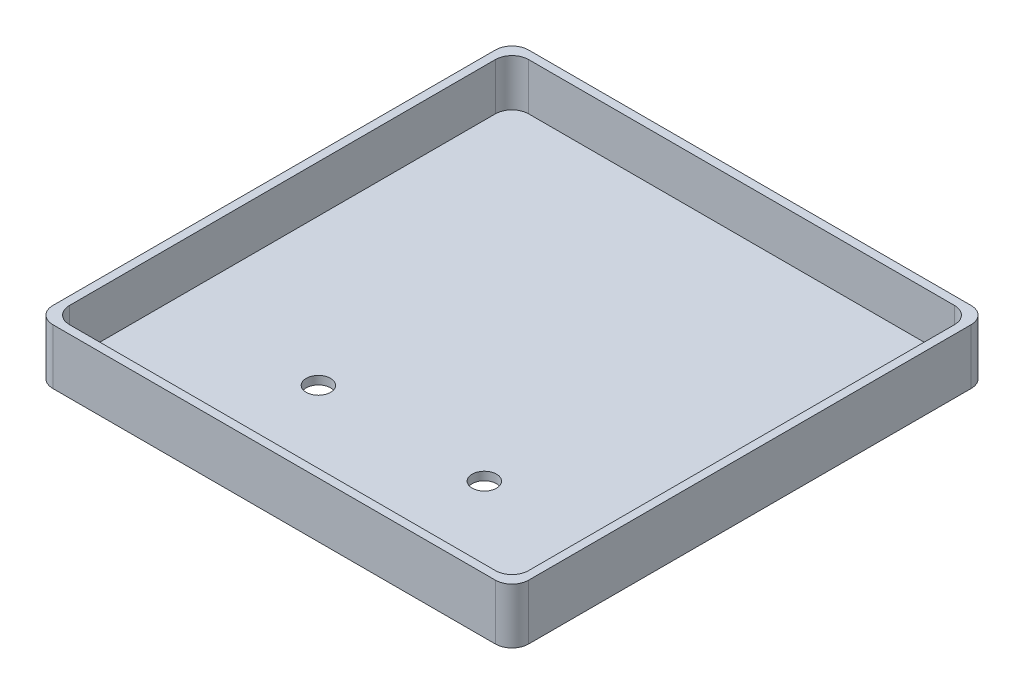
from build123d import *

# Parameters (mm, degrees)
EXTRUDE_1_DEPTH     = 10
CUT_EXTRUDE_1_DEPTH = 8.5
SKETCH_3_R          = 2.2
CUT_EXTRUDE_2_DEPTH = 11


with BuildPart() as part:
    # Эскиз1 → Бобышка-Вытянуть1 (new body)
    with BuildSketch(Plane(origin=(0, 0, 0), x_dir=(1, 0, 0), z_dir=(0, 1, 0))):
        with BuildLine():
            Line((-40, 43), (40, 43))
            ThreePointArc((40, 43), (42.121320344, 42.121320344), (43, 40))
            Line((43, 40), (43, -40))
            ThreePointArc((43, -40), (42.121320344, -42.121320344), (40, -43))
            Line((40, -43), (-40, -43))
            ThreePointArc((-40, -43), (-42.121320344, -42.121320344), (-43, -40))
            Line((-43, -40), (-43, 40))
            ThreePointArc((-43, 40), (-42.121320344, 42.121320344), (-40, 43))
        make_face()
    extrude(amount=EXTRUDE_1_DEPTH)

    # Эскиз2 → Вырез-Вытянуть1 (cut)
    with BuildSketch(Plane(origin=(0, 10, 0), x_dir=(1, 0, 0), z_dir=(0, 1, 0))):
        with BuildLine():
            Line((-38.5, -41.5), (38.5, -41.5))
            ThreePointArc((38.5, -41.5), (40.621320344, -40.621320344), (41.5, -38.5))
            Line((41.5, -38.5), (41.5, 38.5))
            ThreePointArc((41.5, 38.5), (40.621320344, 40.621320344), (38.5, 41.5))
            Line((38.5, 41.5), (-38.5, 41.5))
            ThreePointArc((-38.5, 41.5), (-40.621320344, 40.621320344), (-41.5, 38.5))
            Line((-41.5, 38.5), (-41.5, -38.5))
            ThreePointArc((-41.5, -38.5), (-40.621320344, -40.621320344), (-38.5, -41.5))
        make_face()
    extrude(amount=-CUT_EXTRUDE_1_DEPTH, mode=Mode.SUBTRACT)

    # Эскиз3 → Вырез-Вытянуть2 (cut, through all)
    with BuildSketch(Plane.XZ):
        with Locations((-15, 20)):
            Circle(SKETCH_3_R)
        with Locations((15, 20)):
            Circle(SKETCH_3_R)
    extrude(amount=-CUT_EXTRUDE_2_DEPTH, mode=Mode.SUBTRACT)


solid = part.part
